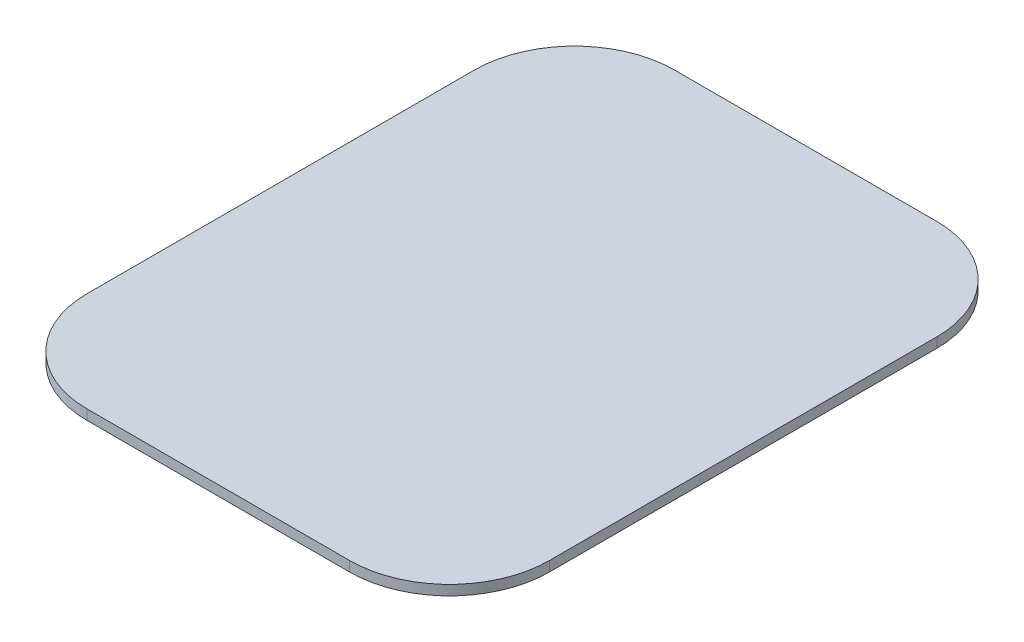
from build123d import *

# Parameters (mm, degrees)
SKETCH1_W           = 185
SKETCH1_H           = 235
BOSS_EXTRUDE1_DEPTH = 4
FILLET1_R           = 40


with BuildPart() as part:
    # Sketch1 → Boss-Extrude1 (new body)
    with BuildSketch(Plane(origin=(0, 0, 0), x_dir=(1, 0, 0), z_dir=(0, 1, 0))):
        Rectangle(SKETCH1_W, SKETCH1_H)
    extrude(amount=BOSS_EXTRUDE1_DEPTH)

    # Fillet1
    fillet1_edges = [part.edges().sort_by_distance(p)[0] for p in [
        (92.5, 2, 117.5),
        (-92.5, 2, 117.5),
        (-92.5, 2, -117.5),
        (92.5, 2, -117.5),
    ]]
    fillet(fillet1_edges, radius=FILLET1_R)


solid = part.part
